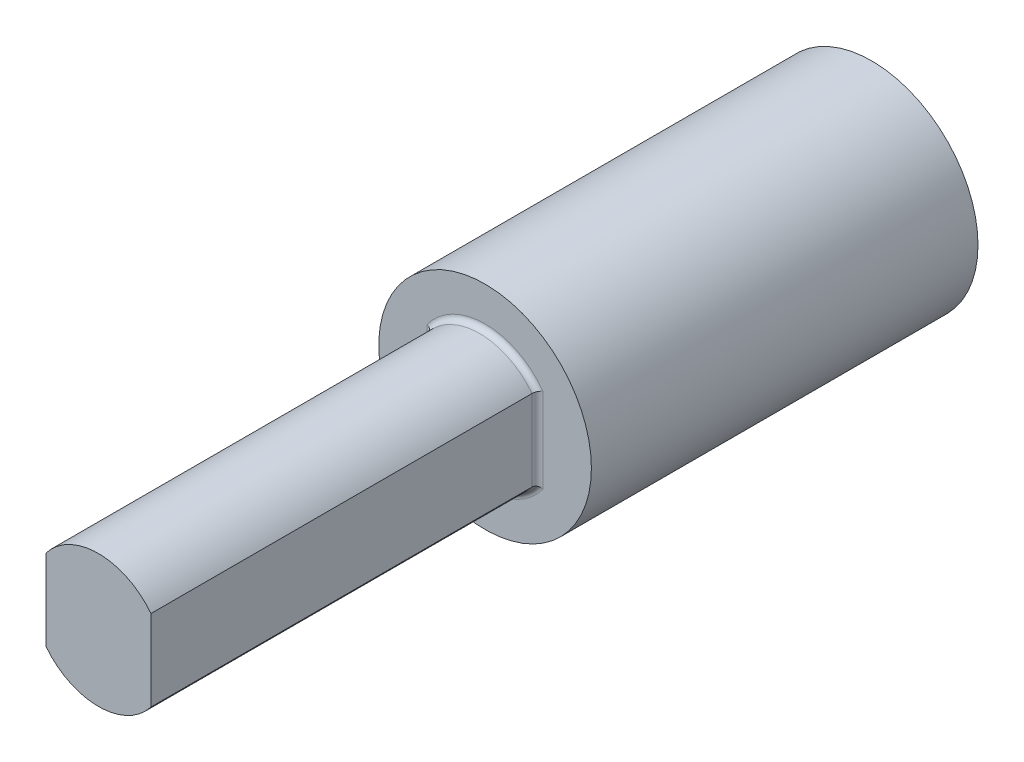
from build123d import *

# Parameters (mm, degrees)
ESQUISSE1_R        = 19.25
BOSS_EXTRU_1_DEPTH = 70
BOSS_EXTRU_2_DEPTH = 70
CONG_1_R           = 1


with BuildPart() as part:
    # Esquisse1 → Boss.-Extru.1 (new body)
    with BuildSketch(Plane.XY):
        Circle(ESQUISSE1_R)
    extrude(amount=-BOSS_EXTRU_1_DEPTH)

    # Esquisse1_4 → Boss.-Extru.2 (add)
    with BuildSketch(Plane.XY):
        with BuildLine():
            Line((-9.5, 7.331439149), (-9.5, -7.331439149))
            ThreePointArc((-9.5, -7.331439149), (0, -12), (9.5, -7.331439149))
            Line((9.5, -7.331439149), (9.5, 7.331439149))
            ThreePointArc((9.5, 7.331439149), (0, 12), (-9.5, 7.331439149))
        make_face()
    extrude(amount=BOSS_EXTRU_2_DEPTH)

    # Congé1
    cong_1_edges = [part.edges().sort_by_distance(p)[0] for p in [
        (0, -12, 0),
        (-9.5, 0, 0),
        (0, 12, 0),
        (9.5, 0, 0),
    ]]
    fillet(cong_1_edges, radius=CONG_1_R)


solid = part.part
